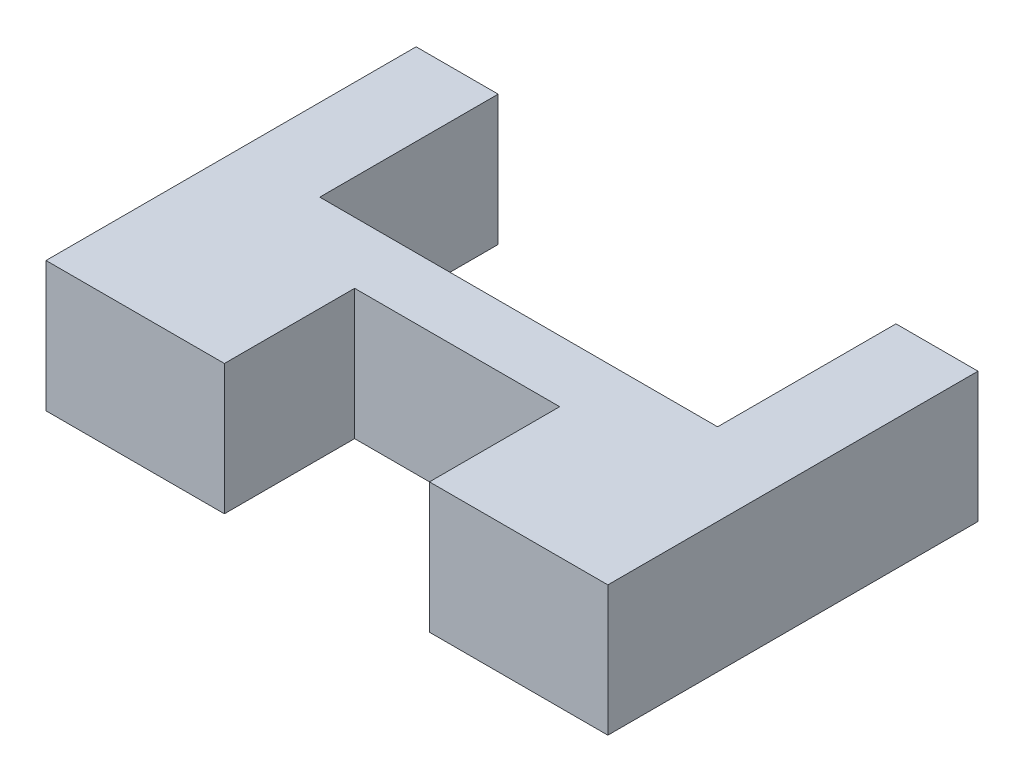
from build123d import *

# Parameters (mm, degrees)
BOSS_EXTRUDE1_DEPTH = 6.35
CUT_EXTRUDE1_REACH  = 8.35
SKETCH2_W           = 10
SKETCH2_H           = 6.35


with BuildPart() as part:
    # Sketch1 → Boss-Extrude1 (new body)
    with BuildSketch(Plane(origin=(0, 0, 0), x_dir=(1, 0, 0), z_dir=(0, 1, 0))):
        Polygon((0, 0), (19.4, 0), (19.4, 8.7), (23.4, 8.7), (23.4, -9.35), (-4, -9.35), (-4, 8.7), (0, 8.7), align=None)
    extrude(amount=BOSS_EXTRUDE1_DEPTH)

    # Sketch2 → Cut-Extrude1 (cut, up to next)
    with BuildSketch(Plane(origin=(0, 6.35, 0), x_dir=(1, 0, 0), z_dir=(0, 1, 0)), mode=Mode.PRIVATE) as cut_extrude1_sk1:
        with Locations((9.7, -6.175)):
            Rectangle(SKETCH2_W, SKETCH2_H)
    cut_extrude1_tool1 = extrude(cut_extrude1_sk1.sketch, amount=-CUT_EXTRUDE1_REACH, mode=Mode.PRIVATE) & part.part
    add(cut_extrude1_tool1.solids().sort_by_distance((9.7, 6.35, 6.175))[0], mode=Mode.SUBTRACT)


solid = part.part
